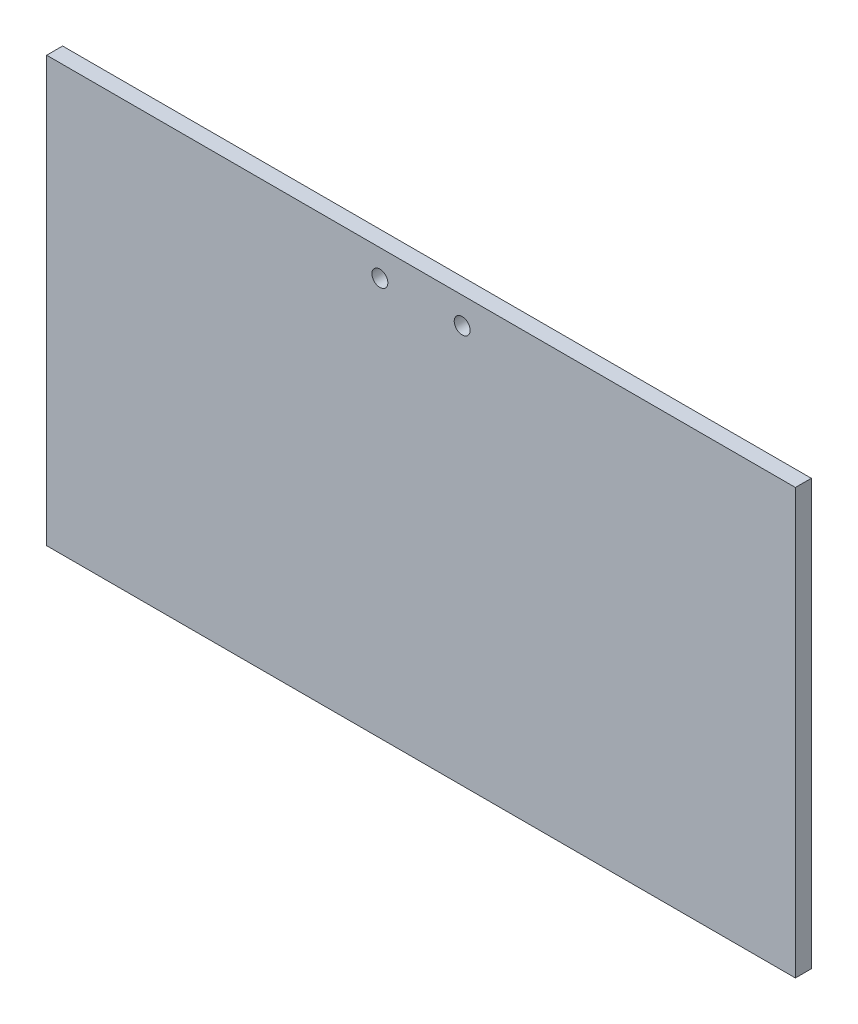
from build123d import *

# Parameters (mm, degrees)
SKETCH_1_W          = 141
SKETCH_1_H          = 80
EXTRUDE_1_DEPTH     = 3
SKETCH_2_R          = 1.5
CUT_EXTRUDE_1_DEPTH = 4


with BuildPart() as part:
    # ｽｹｯﾁ1 → ﾎﾞｽ - 押し出し1 (new body)
    with BuildSketch(Plane.XY):
        with Locations((30.505755396, -2.589928058)):
            Rectangle(SKETCH_1_W, SKETCH_1_H)
    extrude(amount=-EXTRUDE_1_DEPTH)

    # ｽｹｯﾁ2 → ｶｯﾄ - 押し出し1 (cut, through all)
    with BuildSketch(Plane.XY):
        with Locations((22.755755396, 32.410071942)):
            Circle(SKETCH_2_R)
        with Locations((38.255755396, 32.410071942)):
            Circle(SKETCH_2_R)
    extrude(amount=-CUT_EXTRUDE_1_DEPTH, mode=Mode.SUBTRACT)


solid = part.part
